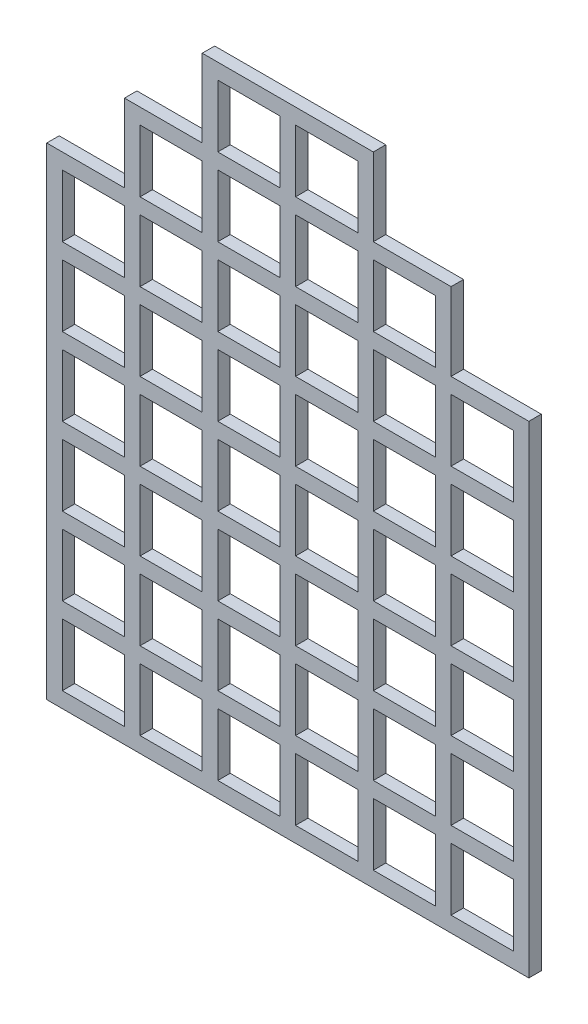
from build123d import *

# Parameters (mm, degrees)
SKETCH_1_W             = 15
SKETCH_1_H             = 0.5
EXTRUDE_1_DEPTH        = 0.4
PATTERN_LINEAR_1_COUNT = 7
PATTERN_LINEAR_1_PITCH = 2.5
EXTRUDE_3_DEPTH        = 0.4
PATTERN_LINEAR_2_COUNT = 7
PATTERN_LINEAR_2_PITCH = 2.5
SKETCH_4_W             = 0.5
SKETCH_4_H             = 2.5
EXTRUDE_4_DEPTH        = 0.4
SKETCH_6_W             = 0.5
SKETCH_6_H             = 2.5
EXTRUDE_6_DEPTH        = 0.4
SKETCH_7_W             = 10.5
SKETCH_7_H             = 0.5
SKETCH_7_W_2           = 5.5
EXTRUDE_7_DEPTH        = 0.4


with BuildPart() as part:
    # Sketch 1 → Extrude 1 (new body)
    with BuildSketch(Plane.XY):
        with Locations((7.5, 0.25)):
            Rectangle(SKETCH_1_W, SKETCH_1_H)
    extrude(amount=EXTRUDE_1_DEPTH)


with BuildPart() as pattern_linear_1_1:
    # Pattern Linear 1: pattern copy
    add(part.part.moved(Location(Vector(0, 1, 0) * (1 * PATTERN_LINEAR_1_PITCH))))


with BuildPart() as pattern_linear_1_2:
    # Pattern Linear 1: pattern copy
    add(part.part.moved(Location(Vector(0, 1, 0) * (2 * PATTERN_LINEAR_1_PITCH))))


with BuildPart() as pattern_linear_1_3:
    # Pattern Linear 1: pattern copy
    add(part.part.moved(Location(Vector(0, 1, 0) * (3 * PATTERN_LINEAR_1_PITCH))))


with BuildPart() as pattern_linear_1_4:
    # Pattern Linear 1: pattern copy
    add(part.part.moved(Location(Vector(0, 1, 0) * (4 * PATTERN_LINEAR_1_PITCH))))


with BuildPart() as pattern_linear_1_5:
    # Pattern Linear 1: pattern copy
    add(part.part.moved(Location(Vector(0, 1, 0) * (5 * PATTERN_LINEAR_1_PITCH))))


with BuildPart() as pattern_linear_1_6:
    # Pattern Linear 1: pattern copy
    add(part.part.moved(Location(Vector(0, 1, 0) * (6 * PATTERN_LINEAR_1_PITCH))))


with BuildPart() as part_1:
    add(part.part)

    add(pattern_linear_1_1.part)  # Extrude 3 merges Pattern Linear 1_1

    add(pattern_linear_1_2.part)  # Extrude 3 merges Pattern Linear 1_2

    add(pattern_linear_1_3.part)  # Extrude 3 merges Pattern Linear 1_3
    # Sketch 3 → Extrude 3 (add)
    with BuildSketch(Plane.XY.offset(0.4)):
        Polygon((0, 15.5), (0, 8), (0, 0), (-0.5, 0), (-0.5, 10.98507125), (-0.5, 15.5), align=None)
    extrude_3 = extrude(amount=-EXTRUDE_3_DEPTH)

    # Pattern Linear 2: Extrude 3 ×7
    with Locations(*[(i * PATTERN_LINEAR_2_PITCH, 0, 0) for i in range(1, PATTERN_LINEAR_2_COUNT)]):
        add(extrude_3)

    add(pattern_linear_1_6.part)  # Extrude 4 merges Pattern Linear 1_6
    # Sketch 4 → Extrude 4 (add)
    with BuildSketch(Plane.XY.offset(0.4)):
        with Locations((4.75, 16.75)):
            Rectangle(SKETCH_4_W, SKETCH_4_H)
        with Locations((2.25, 16.75)):
            Rectangle(SKETCH_4_W, SKETCH_4_H)
        with Locations((7.25, 16.75)):
            Rectangle(SKETCH_4_W, SKETCH_4_H)
        with Locations((9.75, 16.75)):
            Rectangle(SKETCH_4_W, SKETCH_4_H)
        with Locations((12.25, 16.75)):
            Rectangle(SKETCH_4_W, SKETCH_4_H)
    extrude(amount=-EXTRUDE_4_DEPTH)

    # Sketch 6 → Extrude 6 (add)
    with BuildSketch(Plane.XY.offset(0.4)):
        with Locations((4.75, 19.25)):
            Rectangle(SKETCH_6_W, SKETCH_6_H)
        with Locations((9.75, 19.25)):
            Rectangle(SKETCH_6_W, SKETCH_6_H)
        with Locations((7.25, 19.25)):
            Rectangle(SKETCH_6_W, SKETCH_6_H)
    extrude(amount=-EXTRUDE_6_DEPTH)

    # Sketch 7 → Extrude 7 (add)
    with BuildSketch(Plane.XY.offset(0.4)):
        with Locations((7.25, 17.75)):
            Rectangle(SKETCH_7_W, SKETCH_7_H)
        with Locations((7.25, 20.25)):
            Rectangle(SKETCH_7_W_2, SKETCH_7_H)
    extrude(amount=-EXTRUDE_7_DEPTH)

    # Combine 1: union Pattern Linear 1_5, Pattern Linear 1_4
    add(pattern_linear_1_5.part)
    add(pattern_linear_1_4.part)


solid = part_1.part
